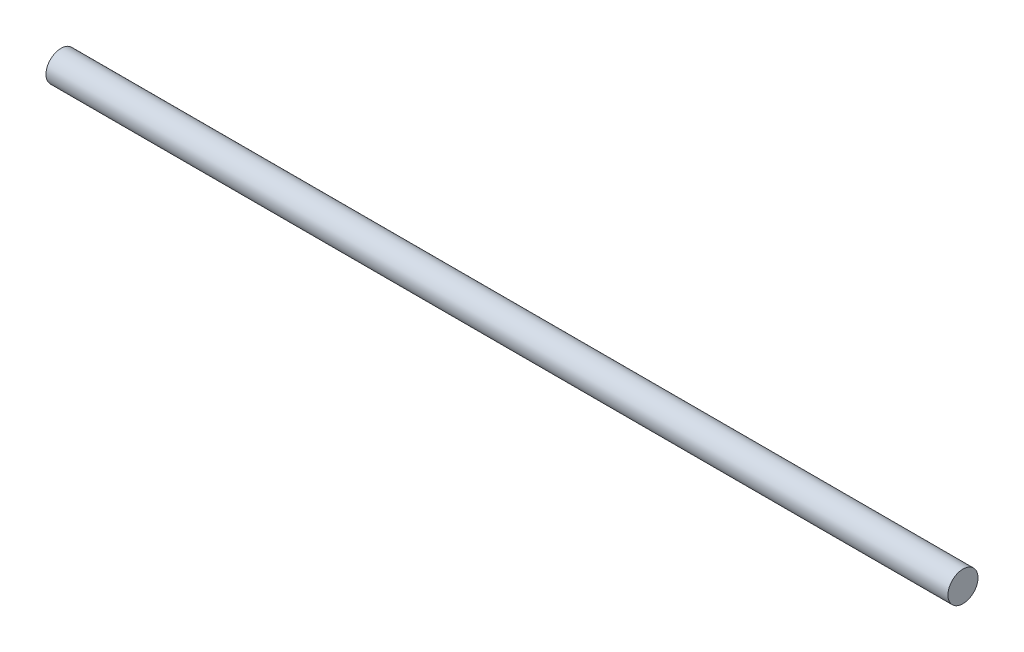
from build123d import *

# Parameters (mm, degrees)
SKETCH1_R           = 5
BOSS_EXTRUDE1_DEPTH = 300


with BuildPart() as part:
    # Sketch1 → Boss-Extrude1 (new body)
    with BuildSketch(Plane(origin=(0, 0, 0), x_dir=(0, 0, -1), z_dir=(1, 0, 0))):
        Circle(SKETCH1_R)
    extrude(amount=BOSS_EXTRUDE1_DEPTH)


solid = part.part
